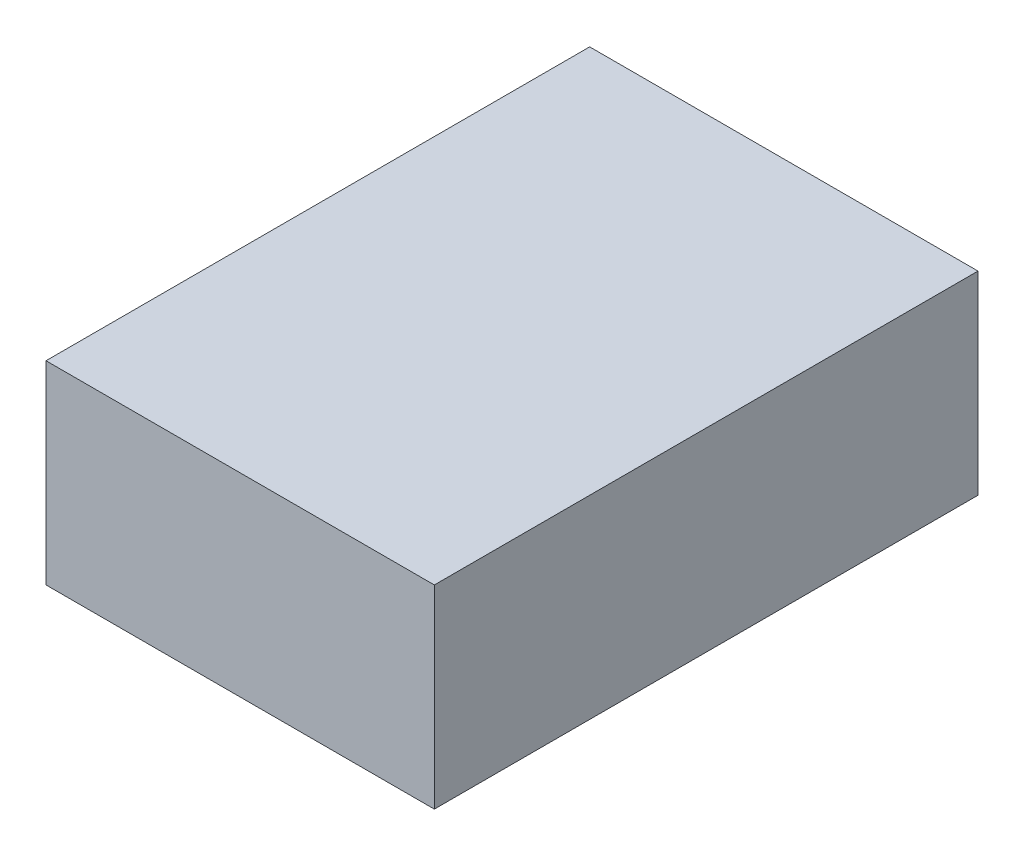
from build123d import *

# Parameters (mm, degrees)
SKETCH2_W           = 127
SKETCH2_H           = 63.5
BOSS_EXTRUDE1_DEPTH = 177.8


with BuildPart() as part:
    # Sketch2 → Boss-Extrude1 (new body)
    with BuildSketch(Plane.XY):
        with Locations((63.5, 31.75)):
            Rectangle(SKETCH2_W, SKETCH2_H)
    extrude(amount=BOSS_EXTRUDE1_DEPTH)


solid = part.part
